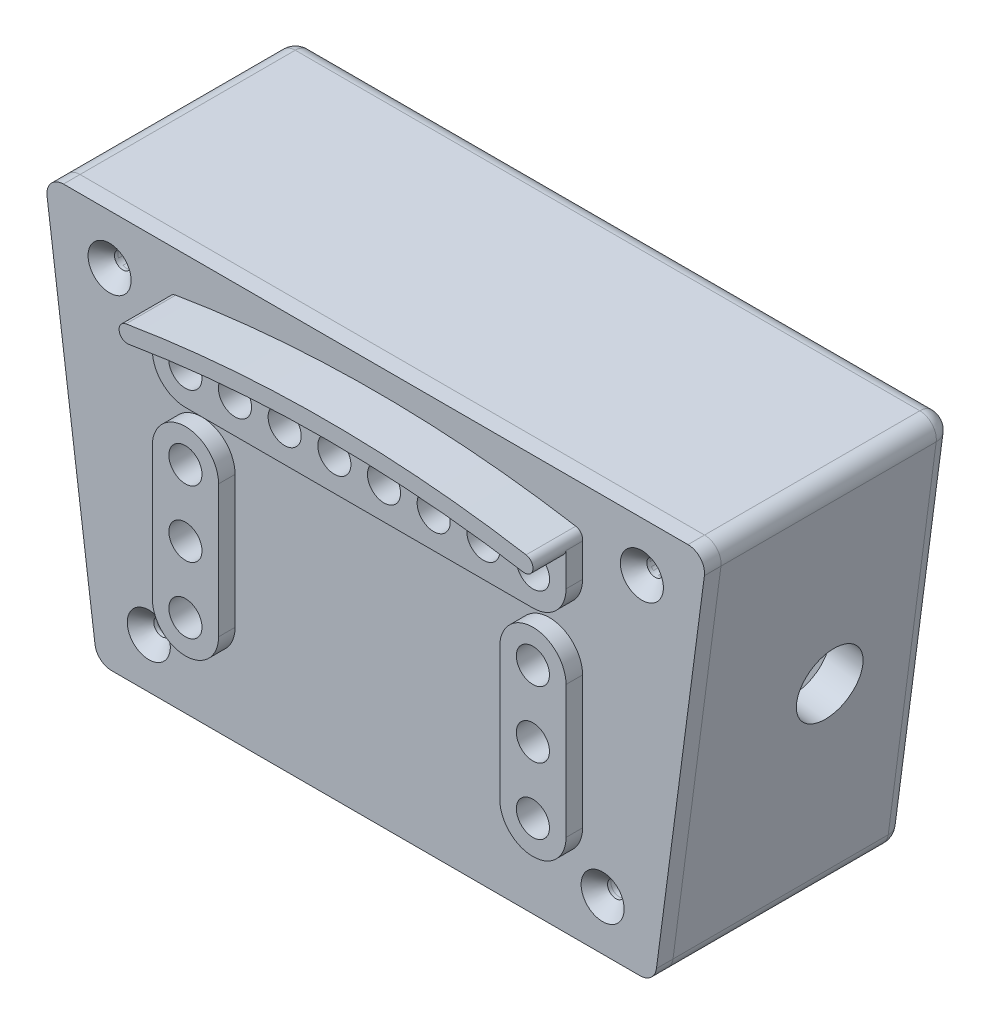
from build123d import *

# Parameters (mm, degrees)
BOSS_EXTRUDE1_DEPTH      = 3.175
BOSS_EXTRUDE2_DEPTH      = 3.175
SKETCH2_R                = 3.175
BOSS_EXTRUDE3_DEPTH      = 6.35
BOSS_EXTRUDE4_DEPTH      = 12.7
SKETCH2_4_R              = 3.175
CUT_EXTRUDE1_DEPTH       = 76.134213245
CUT_EXTRUDE1_DEPTH_BACK  = 76.134213245
FILLET1_R                = 6.35
SKETCH4_R                = 3.175
BOSS_EXTRUDE5_DEPTH      = 6.35
SKETCH4_2_R              = 3.175
CUT_EXTRUDE2_DEPTH       = 76.134213245
CUT_EXTRUDE2_DEPTH_BACK  = 76.134213245
BOSS_EXTRUDE6_DEPTH      = 38.1
BOSS_EXTRUDE7_START      = -38.1
BOSS_EXTRUDE7_DEPTH      = 6.35
BOSS_EXTRUDE11_REACH     = 88.369
SKETCH5_R                = 1.5875
SKETCH5_4_R              = 1.5875
CUT_EXTRUDE9_DEPTH       = 87.36933773
CUT_EXTRUDE9_DEPTH_BACK  = 87.36933773
SKETCH6_R                = 6.35
CUT_EXTRUDE10_DEPTH      = 6.35
CUT_EXTRUDE10_DEPTH_BACK = 510.682305539
CHAMFER1_SIZE            = 2.54
FILLET2_R                = 3.175
FILLET3_R                = 3.175


with BuildPart() as part:
    # Sketch1 → Boss-Extrude1 (new body)
    with BuildSketch(Plane.XY):
        Polygon((-53.468079684, -38.1), (53.468079684, -38.1), (63.5, 38.1), (-63.5, 38.1), align=None)
        Polygon((47.899279144, -31.75), (56.259212741, 31.75), (-56.259212741, 31.75), (-47.899279144, -31.75), align=None, mode=Mode.SUBTRACT)
        Polygon((-47.899279144, -31.75), (47.899279144, -31.75), (56.259212741, 31.75), (-56.259212741, 31.75), align=None)
    extrude(amount=BOSS_EXTRUDE1_DEPTH)

    # Sketch1_3 → Boss-Extrude2 (add)
    with BuildSketch(Plane.XY):
        Polygon((-47.899279144, -31.75), (47.899279144, -31.75), (56.259212741, 31.75), (-56.259212741, 31.75), align=None)
    extrude(amount=-BOSS_EXTRUDE2_DEPTH)

    # Sketch2 → Boss-Extrude3 (add)
    with BuildSketch(Plane.XY):
        with BuildLine():
            ThreePointArc((-37.837241379, 27.272155172), (-39.021250412, 27.544911403), (-39.665603448, 28.575))
            Line((-39.665603448, 28.575), (-39.665603448, 15.875))
            Line((-39.665603448, 15.875), (39.665603448, 15.875))
            Line((39.665603448, 15.875), (39.665603448, 28.575))
            ThreePointArc((39.665603448, 28.575), (39.021250412, 27.544911403), (37.837241379, 27.272155172))
            ThreePointArc((37.837241379, 27.272155172), (0, 30.425258621), (-37.837241379, 27.272155172))
        make_face()
        with Locations((-33.3375, 22.225)):
            Circle(SKETCH2_R, mode=Mode.SUBTRACT)
        with Locations((-23.8125, 22.225)):
            Circle(SKETCH2_R, mode=Mode.SUBTRACT)
        with Locations((-14.2875, 22.225)):
            Circle(SKETCH2_R, mode=Mode.SUBTRACT)
        with Locations((-4.7625, 22.225)):
            Circle(SKETCH2_R, mode=Mode.SUBTRACT)
        with Locations((4.7625, 22.225)):
            Circle(SKETCH2_R, mode=Mode.SUBTRACT)
        with Locations((14.2875, 22.225)):
            Circle(SKETCH2_R, mode=Mode.SUBTRACT)
        with Locations((23.8125, 22.225)):
            Circle(SKETCH2_R, mode=Mode.SUBTRACT)
        with Locations((33.3375, 22.225)):
            Circle(SKETCH2_R, mode=Mode.SUBTRACT)
        with Locations((-33.3375, 22.225)):
            Circle(SKETCH2_R)
        with Locations((-23.8125, 22.225)):
            Circle(SKETCH2_R)
        with Locations((-14.2875, 22.225)):
            Circle(SKETCH2_R)
        with Locations((-4.7625, 22.225)):
            Circle(SKETCH2_R)
        with Locations((4.7625, 22.225)):
            Circle(SKETCH2_R)
        with Locations((14.2875, 22.225)):
            Circle(SKETCH2_R)
        with Locations((23.8125, 22.225)):
            Circle(SKETCH2_R)
        with Locations((33.3375, 22.225)):
            Circle(SKETCH2_R)
        with BuildLine():
            ThreePointArc((-37.837241379, 27.272155172), (0, 30.425258621), (37.837241379, 27.272155172))
            ThreePointArc((37.837241379, 27.272155172), (39.665603448, 28.575), (38.362758621, 30.403362069))
            ThreePointArc((38.362758621, 30.403362069), (0, 33.600258621), (-38.362758621, 30.403362069))
            ThreePointArc((-38.362758621, 30.403362069), (-39.665603448, 28.575), (-37.837241379, 27.272155172))
        make_face()
    extrude(amount=BOSS_EXTRUDE3_DEPTH)

    # Sketch2_3 → Boss-Extrude4 (add)
    with BuildSketch(Plane.XY):
        with BuildLine():
            ThreePointArc((-37.837241379, 27.272155172), (0, 30.425258621), (37.837241379, 27.272155172))
            ThreePointArc((37.837241379, 27.272155172), (39.665603448, 28.575), (38.362758621, 30.403362069))
            ThreePointArc((38.362758621, 30.403362069), (0, 33.600258621), (-38.362758621, 30.403362069))
            ThreePointArc((-38.362758621, 30.403362069), (-39.665603448, 28.575), (-37.837241379, 27.272155172))
        make_face()
    extrude(amount=BOSS_EXTRUDE4_DEPTH)

    # Sketch2_4 → Cut-Extrude1 (cut, two sides)
    with BuildSketch(Plane.XY) as cut_extrude1_sk:
        with Locations((-33.3375, 22.225)):
            Circle(SKETCH2_4_R)
        with Locations((-23.8125, 22.225)):
            Circle(SKETCH2_4_R)
        with Locations((-14.2875, 22.225)):
            Circle(SKETCH2_4_R)
        with Locations((-4.7625, 22.225)):
            Circle(SKETCH2_4_R)
        with Locations((4.7625, 22.225)):
            Circle(SKETCH2_4_R)
        with Locations((14.2875, 22.225)):
            Circle(SKETCH2_4_R)
        with Locations((23.8125, 22.225)):
            Circle(SKETCH2_4_R)
        with Locations((33.3375, 22.225)):
            Circle(SKETCH2_4_R)
    extrude(amount=CUT_EXTRUDE1_DEPTH, mode=Mode.SUBTRACT)
    extrude(cut_extrude1_sk.sketch, amount=-CUT_EXTRUDE1_DEPTH_BACK, mode=Mode.SUBTRACT)

    # Fillet1
    fillet1_edges = [part.edges().sort_by_distance(p)[0] for p in [
        (39.665603448, 15.875, 4.7625),
        (-39.665603448, 15.875, 4.7625),
    ]]
    fillet(fillet1_edges, radius=FILLET1_R)

    # Sketch4 → Boss-Extrude5 (add)
    with BuildSketch(Plane.XY):
        with BuildLine():
            Line((-26.965603448, 6.35), (-26.965603448, -19.05))
            ThreePointArc((-26.965603448, -19.05), (-33.315603448, -25.4), (-39.665603448, -19.05))
            Line((-39.665603448, -19.05), (-39.665603448, 6.35))
            ThreePointArc((-39.665603448, 6.35), (-33.315603448, 12.7), (-26.965603448, 6.35))
        make_face()
        with Locations((-33.315603448, 6.35)):
            Circle(SKETCH4_R, mode=Mode.SUBTRACT)
        with Locations((-33.315603448, -6.35)):
            Circle(SKETCH4_R, mode=Mode.SUBTRACT)
        with Locations((-33.315603448, -19.05)):
            Circle(SKETCH4_R, mode=Mode.SUBTRACT)
        with BuildLine():
            Line((39.665603448, 6.35), (39.665603448, -19.05))
            ThreePointArc((39.665603448, -19.05), (33.315603448, -25.4), (26.965603448, -19.05))
            Line((26.965603448, -19.05), (26.965603448, 6.35))
            ThreePointArc((26.965603448, 6.35), (33.315603448, 12.7), (39.665603448, 6.35))
        make_face()
        with Locations((33.315603448, 6.35)):
            Circle(SKETCH4_R, mode=Mode.SUBTRACT)
        with Locations((33.315603448, -6.35)):
            Circle(SKETCH4_R, mode=Mode.SUBTRACT)
        with Locations((33.315603448, -19.05)):
            Circle(SKETCH4_R, mode=Mode.SUBTRACT)
    extrude(amount=BOSS_EXTRUDE5_DEPTH)

    # Sketch4_2 → Cut-Extrude2 (cut, two sides)
    with BuildSketch(Plane.XY) as cut_extrude2_sk:
        with Locations((-33.315603448, 6.35)):
            Circle(SKETCH4_2_R)
        with Locations((-33.315603448, -6.35)):
            Circle(SKETCH4_2_R)
        with Locations((-33.315603448, -19.05)):
            Circle(SKETCH4_2_R)
        with Locations((33.315603448, -19.05)):
            Circle(SKETCH4_2_R)
        with Locations((33.315603448, -6.35)):
            Circle(SKETCH4_2_R)
        with Locations((33.315603448, 6.35)):
            Circle(SKETCH4_2_R)
    extrude(amount=CUT_EXTRUDE2_DEPTH, mode=Mode.SUBTRACT)
    extrude(cut_extrude2_sk.sketch, amount=-CUT_EXTRUDE2_DEPTH_BACK, mode=Mode.SUBTRACT)

    # Sketch5_4 → Cut-Extrude9 (cut, two sides)
    with BuildSketch(Plane.XY) as cut_extrude9_sk:
        with Locations((-51.037620636, 28.575)):
            Circle(SKETCH5_4_R)
        with Locations((-43.513680399, -28.575)):
            Circle(SKETCH5_4_R)
        with Locations((43.513680399, -28.575)):
            Circle(SKETCH5_4_R)
        with Locations((51.037620636, 28.575)):
            Circle(SKETCH5_4_R)
    extrude(amount=CUT_EXTRUDE9_DEPTH, mode=Mode.SUBTRACT)
    extrude(cut_extrude9_sk.sketch, amount=-CUT_EXTRUDE9_DEPTH_BACK, mode=Mode.SUBTRACT)

    # Chamfer1
    chamfer1_edges = [part.edges().sort_by_distance(p)[0] for p in [
        (-52.625120636, 28.575, 3.175),
        (-45.101180399, -28.575, 3.175),
        (41.926180399, -28.575, 3.175),
        (49.450120636, 28.575, 3.175),
    ]]
    chamfer(chamfer1_edges, length=CHAMFER1_SIZE)

    # Fillet3
    fillet3_edges = [part.edges().sort_by_distance(p)[0] for p in [
        (-53.468079684, -38.1, 1.5875),
        (-63.5, 38.1, 1.5875),
        (63.5, 38.1, 1.5875),
        (53.468079684, -38.1, 1.5875),
    ]]
    fillet(fillet3_edges, radius=FILLET3_R)


with BuildPart() as body_2:
    # Sketch1_4 → Boss-Extrude6 (new body)
    with BuildSketch(Plane.XY):
        Polygon((-53.468079684, -38.1), (53.468079684, -38.1), (63.5, 38.1), (-63.5, 38.1), align=None)
        Polygon((47.899279144, -31.75), (56.259212741, 31.75), (-56.259212741, 31.75), (-47.899279144, -31.75), align=None, mode=Mode.SUBTRACT)
    extrude(amount=-BOSS_EXTRUDE6_DEPTH)

    # Sketch1_5 → Boss-Extrude7 (add)
    with BuildSketch(Plane.XY.offset(BOSS_EXTRUDE7_START)):
        Polygon((-53.468079684, -38.1), (53.468079684, -38.1), (63.5, 38.1), (-63.5, 38.1), align=None)
        Polygon((47.899279144, -31.75), (56.259212741, 31.75), (-56.259212741, 31.75), (-47.899279144, -31.75), align=None, mode=Mode.SUBTRACT)
        Polygon((-47.899279144, -31.75), (47.899279144, -31.75), (56.259212741, 31.75), (-56.259212741, 31.75), align=None)
    extrude(amount=-BOSS_EXTRUDE7_DEPTH)

    # Sketch5 → Boss-Extrude11 (add, up to next)
    with BuildSketch(Plane.XY, mode=Mode.PRIVATE) as boss_extrude11_sk1:
        with BuildLine():
            Line((-56.259212741, 31.75), (-55.211149786, 23.789171499))
            ThreePointArc((-55.211149786, 23.789171499), (-48.408876649, 22.794670853), (-44.687620636, 28.575))
            ThreePointArc((-44.687620636, 28.575), (-44.903991639, 30.218500936), (-45.538359322, 31.75))
            Line((-45.538359322, 31.75), (-56.259212741, 31.75))
        make_face()
        with Locations((-51.037620636, 28.575)):
            Circle(SKETCH5_R, mode=Mode.SUBTRACT)
    boss_extrude11_tool1 = extrude(boss_extrude11_sk1.sketch, amount=-BOSS_EXTRUDE11_REACH, mode=Mode.PRIVATE) - body_2.part
    # Sketch5 → Boss-Extrude11 (add, up to next)
    with BuildSketch(Plane.XY, mode=Mode.PRIVATE) as boss_extrude11_sk2:
        with BuildLine():
            Line((-48.783663554, -25.03243348), (-47.899279144, -31.75))
            Line((-47.899279144, -31.75), (-38.014419085, -31.75))
            ThreePointArc((-38.014419085, -31.75), (-37.380051402, -30.218500936), (-37.163680399, -28.575))
            ThreePointArc((-37.163680399, -28.575), (-41.661910034, -22.501002427), (-48.783663554, -25.03243348))
        make_face()
        with Locations((-43.513680399, -28.575)):
            Circle(SKETCH5_R, mode=Mode.SUBTRACT)
    boss_extrude11_tool2 = extrude(boss_extrude11_sk2.sketch, amount=-BOSS_EXTRUDE11_REACH, mode=Mode.PRIVATE) - body_2.part
    # Sketch5 → Boss-Extrude11 (add, up to next)
    with BuildSketch(Plane.XY, mode=Mode.PRIVATE) as boss_extrude11_sk3:
        with BuildLine():
            ThreePointArc((48.783663554, -25.03243348), (40.152941328, -23.187242313), (38.014419085, -31.75))
            Line((38.014419085, -31.75), (47.899279144, -31.75))
            Line((47.899279144, -31.75), (48.783663554, -25.03243348))
        make_face()
        with Locations((43.513680399, -28.575)):
            Circle(SKETCH5_R, mode=Mode.SUBTRACT)
    boss_extrude11_tool3 = extrude(boss_extrude11_sk3.sketch, amount=-BOSS_EXTRUDE11_REACH, mode=Mode.PRIVATE) - body_2.part
    # Sketch5 → Boss-Extrude11 (add, up to next)
    with BuildSketch(Plane.XY, mode=Mode.PRIVATE) as boss_extrude11_sk4:
        with BuildLine():
            ThreePointArc((45.538359322, 31.75), (47.002389658, 23.671999801), (55.211149786, 23.789171499))
            Line((55.211149786, 23.789171499), (56.259212741, 31.75))
            Line((56.259212741, 31.75), (45.538359322, 31.75))
        make_face()
        with Locations((51.037620636, 28.575)):
            Circle(SKETCH5_R, mode=Mode.SUBTRACT)
    boss_extrude11_tool4 = extrude(boss_extrude11_sk4.sketch, amount=-BOSS_EXTRUDE11_REACH, mode=Mode.PRIVATE) - body_2.part
    add(boss_extrude11_tool1.solids().sort_by_distance((-48.470922, 22.931101, 0))[0])
    add(boss_extrude11_tool2.solids().sort_by_distance((-48.192507, -28.371605, 0))[0])
    add(boss_extrude11_tool3.solids().sort_by_distance((40.232461, -23.314724, 0))[0])
    add(boss_extrude11_tool4.solids().sort_by_distance((47.097631, 23.787723, 0))[0])

    # Sketch6 → Cut-Extrude10 (cut, two sides)
    with BuildSketch(Plane(origin=(-2.773412859, -465.296548287, 0), x_dir=(0, 0, -1), z_dir=(-0.9914448613738105, 0.1305261922200517, 0))) as cut_extrude10_sk:
        with Locations(Location((25.4, -469.31157386, 0), (0, 0, 90))):
            Circle(SKETCH6_R)
    extrude(amount=CUT_EXTRUDE10_DEPTH, mode=Mode.SUBTRACT)
    extrude(cut_extrude10_sk.sketch, amount=-CUT_EXTRUDE10_DEPTH_BACK, mode=Mode.SUBTRACT)

    # Fillet2
    fillet2_edges = [body_2.edges().sort_by_distance(p)[0] for p in [
        (-53.468079684, -38.1, -22.225),
        (-63.5, 38.1, -22.225),
        (63.5, 38.1, -22.225),
        (53.468079684, -38.1, -22.225),
        (0, -38.1, -44.45),
        (58.484039842, 0, -44.45),
        (-58.484039842, 0, -44.45),
        (0, 38.1, -44.45),
    ]]
    fillet(fillet2_edges, radius=FILLET2_R)


solid = Compound([part.part, body_2.part])
